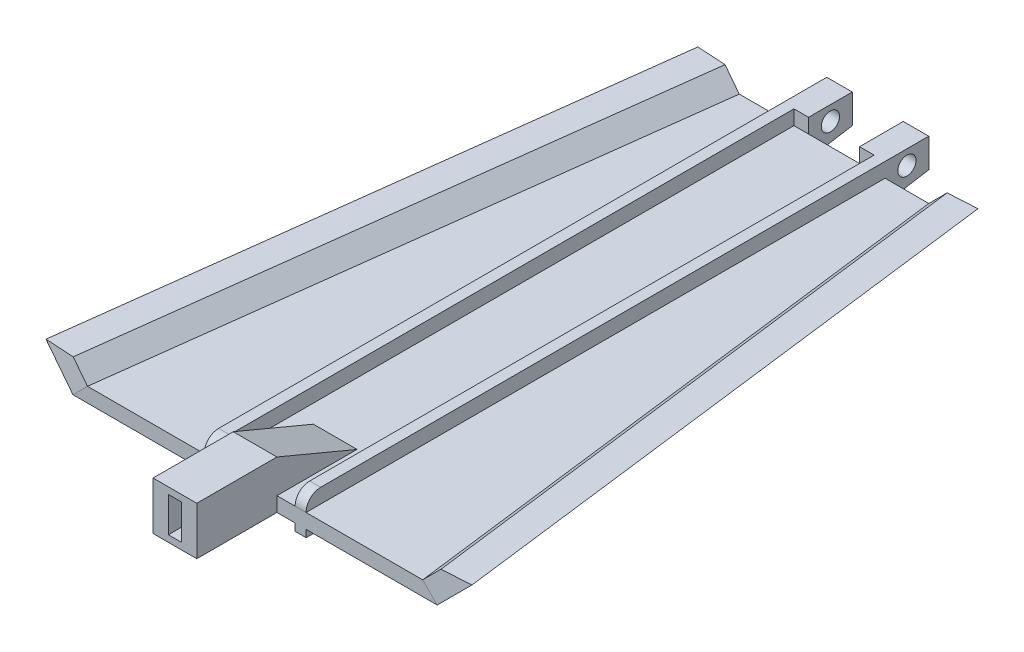
from build123d import *

# Parameters (mm, degrees)
BOSS_EXTRUDE1_DEPTH       = 2
BOSS_EXTRUDE2_DEPTH       = 6
BOSS_EXTRUDE3_DEPTH       = 6
SKETCH14_W                = 1.5
SKETCH14_H                = 79.45913029
BOSS_EXTRUDE4_DEPTH       = 2
BOSS_EXTRUDE5_DEPTH       = 11
SKETCH19_W                = 1.8
SKETCH19_H                = 4.8
CUT_EXTRUDE2_DEPTH        = 11
BOSS_EXTRUDE7_DEPTH       = 6
SKETCH21_W                = 1.5
SKETCH21_H                = 4
BOSS_EXTRUDE8_DEPTH       = 6
SKETCH24_W                = 6
SKETCH24_H                = 4
BOSS_EXTRUDE9_DEPTH       = 3.5
SKETCH25_W                = 6
SKETCH25_H                = 4
BOSS_EXTRUDE10_DEPTH      = 3.5
SKETCH22_R                = 1.25
CUT_EXTRUDE3_DEPTH        = 23.5
SKETCH27_W                = 1.5
SKETCH27_H                = 79.45913029
BOSS_EXTRUDE11_DEPTH      = 5
BOSS_EXTRUDE12_DEPTH      = 2
BOSS_EXTRUDE12_DEPTH_BACK = 1.5
BOSS_EXTRUDE13_DEPTH      = 3.5
BOSS_EXTRUDE14_DEPTH      = 2
BOSS_EXTRUDE15_DEPTH      = 2
FILLET2_R                 = 2


with BuildPart() as part:
    # Sketch1 → Boss-Extrude1 (new body)
    with BuildSketch(Plane(origin=(0, 0, 0), x_dir=(1, 0, 0), z_dir=(0, 1, 0))):
        Polygon((-21.058581006, -39.654130901), (28.941418994, -39.654130901), (18.941418994, 39.804999389), (-11.058581006, 39.804999389), align=None)
    extrude(amount=BOSS_EXTRUDE1_DEPTH)

    # Sketch2 → Cut-Loft1 section 0
    with BuildSketch(Plane.XY.offset(39.654130901)):
        Polygon((-21.058581006, 2), (-21.058581006, 0), (-19.058581006, 2), align=None)
    # Sketch3 → Cut-Loft1 section 1
    with BuildSketch(Plane(origin=(0, 0, -39.804999389), x_dir=(-1, 0, 0), z_dir=(0, 0, -1))):
        Polygon((11.058581006, 0), (11.058581006, 2), (9.058581006, 2), align=None)
    loft(mode=Mode.SUBTRACT)

    # Sketch5 → Cut-Loft2 section 0
    with BuildSketch(Plane(origin=(0, 0, -39.804999389), x_dir=(-1, 0, 0), z_dir=(0, 0, -1))):
        Polygon((-18.941418994, 0), (-18.941418994, 2), (-16.941418994, 2), align=None)
    # Sketch4 → Cut-Loft2 section 1
    with BuildSketch(Plane.XY.offset(39.654130901)):
        Polygon((28.941418994, 0), (28.941418994, 2), (26.941418994, 2), align=None)
    loft(mode=Mode.SUBTRACT)

    # Sketch6 → Boss-Extrude2 (add)
    with BuildSketch(Plane(origin=(11.881365089, 11.881365089, -1.495280032), x_dir=(-0.062677741, -0.062677741, -0.996063754), z_dir=(0.704323435, 0.704323435, -0.088639711))):
        Polygon((-41.312025236, -20.464673628), (38.461111762, -13.393605816), (38.461111762, -10.565178691), (-41.312025236, -17.636246503), align=None)
    extrude(amount=BOSS_EXTRUDE2_DEPTH)

    # Sketch7 → Boss-Extrude3 (add)
    with BuildSketch(Plane(origin=(-7.970913818, 7.970913818, -1.003146371), x_dir=(-0.062677741, 0.062677741, 0.996063754), z_dir=(-0.704323435, 0.704323435, -0.088639711))):
        Polygon((-38.955190238, -4.991170495), (40.81794676, -12.062238307), (40.81794676, -14.890665432), (-38.955190238, -7.81959762), align=None)
    extrude(amount=BOSS_EXTRUDE3_DEPTH)

    # Sketch9 → Cut-Loft3 section 0
    with BuildSketch(Plane(origin=(2.441623315, -2.441623315, -38.801853018), x_dir=(-0.998033817, -0.003936239, -0.062554018), z_dir=(0.062677741, -0.062677741, -0.996063754))):
        Polygon((17.761066429, 6.750801427), (13.768931159, 6.750801427), (15.757126317, 8.746853538), align=None)
    # Sketch8 → Cut-Loft3 section 1
    with BuildSketch(Plane(origin=(-2.558376685, 2.558376685, 40.657277272), x_dir=(0.998033817, 0.003936239, 0.062554018), z_dir=(-0.062677741, 0.062677741, 0.996063754))):
        Polygon((-22.770916709, 1.760671151), (-18.778781439, 1.760671151), (-20.766976597, 3.756723262), align=None)
    loft(mode=Mode.SUBTRACT)

    # Sketch13 → Cut-Loft4 section 0
    with BuildSketch(Plane(origin=(2.589344408, 2.589344408, 41.149410933), x_dir=(0.998033817, -0.003936239, -0.062554018), z_dir=(0.062677741, 0.062677741, 0.996063754))):
        Polygon((30.638255597, 1.760671151), (26.646120328, 1.760671151), (28.634315485, 3.756723262), align=None)
    # Sketch12 → Cut-Loft4 section 1
    with BuildSketch(Plane(origin=(-2.410655592, -2.410655592, -38.309719357), x_dir=(-0.998033817, 0.003936239, 0.062554018), z_dir=(-0.062677741, -0.062677741, -0.996063754))):
        Polygon((-25.628405317, 6.750801427), (-21.636270047, 6.750801427), (-23.624465205, 8.746853538), align=None)
    loft(mode=Mode.SUBTRACT)

    # Sketch14 → Boss-Extrude4 (add)
    with BuildSketch(Plane(origin=(0, 2, 0), x_dir=(1, 0, 0), z_dir=(0, 1, 0))):
        with Locations((10.191418994, 0.075434244)):
            Rectangle(SKETCH14_W, SKETCH14_H)
        with Locations((-2.308581006, 0.075434244)):
            Rectangle(SKETCH14_W, SKETCH14_H)
    extrude(amount=BOSS_EXTRUDE4_DEPTH)

    # Sketch15 → Boss-Extrude5 (add)
    with BuildSketch(Plane.XY.offset(39.654130901)):
        Polygon((3.941418994, 0), (6.941418994, 0), (6.941418994, 6.6), (0.941418994, 6.6), (0.941418994, 0), align=None)
    extrude(amount=BOSS_EXTRUDE5_DEPTH)

    # Sketch19 → Cut-Extrude2 (cut)
    with BuildSketch(Plane.XY.offset(50.654130901)):
        with Locations((3.941418994, 3.3)):
            Rectangle(SKETCH19_W, SKETCH19_H)
    extrude(amount=-CUT_EXTRUDE2_DEPTH, mode=Mode.SUBTRACT)

    # Sketch20 → Boss-Extrude7 (add)
    with BuildSketch(Plane.ZY.offset(-0.941418994)):
        Polygon((39.654130901, 2), (28.654130901, 2), (39.654130901, 6.6), align=None)
    extrude(amount=-BOSS_EXTRUDE7_DEPTH)

    # Sketch21 → Boss-Extrude8 (add)
    with BuildSketch(Plane(origin=(0, 0, -39.804999389), x_dir=(-1, 0, 0), z_dir=(0, 0, -1))):
        with Locations((-10.191418994, 2)):
            Rectangle(SKETCH21_W, SKETCH21_H)
        with Locations((2.308581006, 2)):
            Rectangle(SKETCH21_W, SKETCH21_H)
    extrude(amount=BOSS_EXTRUDE8_DEPTH)

    # Sketch24 → Boss-Extrude9 (add)
    with BuildSketch(Plane.ZY.offset(3.058581006)):
        with Locations((-42.804999389, 2)):
            Rectangle(SKETCH24_W, SKETCH24_H)
    extrude(amount=-BOSS_EXTRUDE9_DEPTH)

    # Sketch25 → Boss-Extrude10 (add)
    with BuildSketch(Plane(origin=(10.941418994, 0, 0), x_dir=(0, 0, -1), z_dir=(1, 0, 0))):
        with Locations((42.804999389, 2)):
            Rectangle(SKETCH25_W, SKETCH25_H)
    extrude(amount=-BOSS_EXTRUDE10_DEPTH)

    # Sketch22 → Cut-Extrude3 (cut)
    with BuildSketch(Plane(origin=(10.941418994, 0, 0), x_dir=(0, 0, -1), z_dir=(1, 0, 0))):
        with Locations((42.804999389, 2)):
            Circle(SKETCH22_R)
    extrude(amount=-CUT_EXTRUDE3_DEPTH, mode=Mode.SUBTRACT)

    # Sketch27 → Boss-Extrude11 (add)
    with BuildSketch(Plane(origin=(0, 4, 0), x_dir=(1, 0, 0), z_dir=(0, 1, 0))):
        with Locations((-2.308581006, 0.075434244)):
            Rectangle(SKETCH27_W, SKETCH27_H)
        with Locations((10.191418994, 0.075434244)):
            Rectangle(SKETCH27_W, SKETCH27_H)
    extrude(amount=-BOSS_EXTRUDE11_DEPTH)

    # Sketch28 → Boss-Extrude12 (add, two sides)
    with BuildSketch(Plane(origin=(-1.558581006, 0, 0), x_dir=(0, 0, -1), z_dir=(1, 0, 0))) as boss_extrude12_sk:
        Polygon((39.804999389, -1), (39.804999389, 0), (45.848869538, 0), align=None)
    extrude(amount=BOSS_EXTRUDE12_DEPTH)
    extrude(boss_extrude12_sk.sketch, amount=-BOSS_EXTRUDE12_DEPTH_BACK)

    # Sketch29 → Boss-Extrude13 (add)
    with BuildSketch(Plane(origin=(10.941418994, 0, 0), x_dir=(0, 0, -1), z_dir=(1, 0, 0))):
        Polygon((39.804999389, 0), (45.804999389, 0), (39.804999389, -1), align=None)
    extrude(amount=-BOSS_EXTRUDE13_DEPTH)

    # Sketch31 → Boss-Extrude14 (add)
    with BuildSketch(Plane(origin=(-1.558581006, 0, 0), x_dir=(0, 0, -1), z_dir=(1, 0, 0))):
        Polygon((39.804999389, -1), (35.804999389, 0), (39.804999389, 0), align=None)
    extrude(amount=BOSS_EXTRUDE14_DEPTH)

    # Sketch32 → Boss-Extrude15 (add)
    with BuildSketch(Plane.ZY.offset(-9.441418994)):
        Polygon((-39.804999389, 0), (-39.804999389, -1), (-35.804999389, 0), align=None)
    extrude(amount=BOSS_EXTRUDE15_DEPTH)

    # Fillet2
    fillet2_edges = [part.edges().sort_by_distance(p)[0] for p in [
        (10.191418994, 4, 39.654130901),
        (-2.308581006, 4, 39.654130901),
    ]]
    fillet(fillet2_edges, radius=FILLET2_R)


solid = part.part
